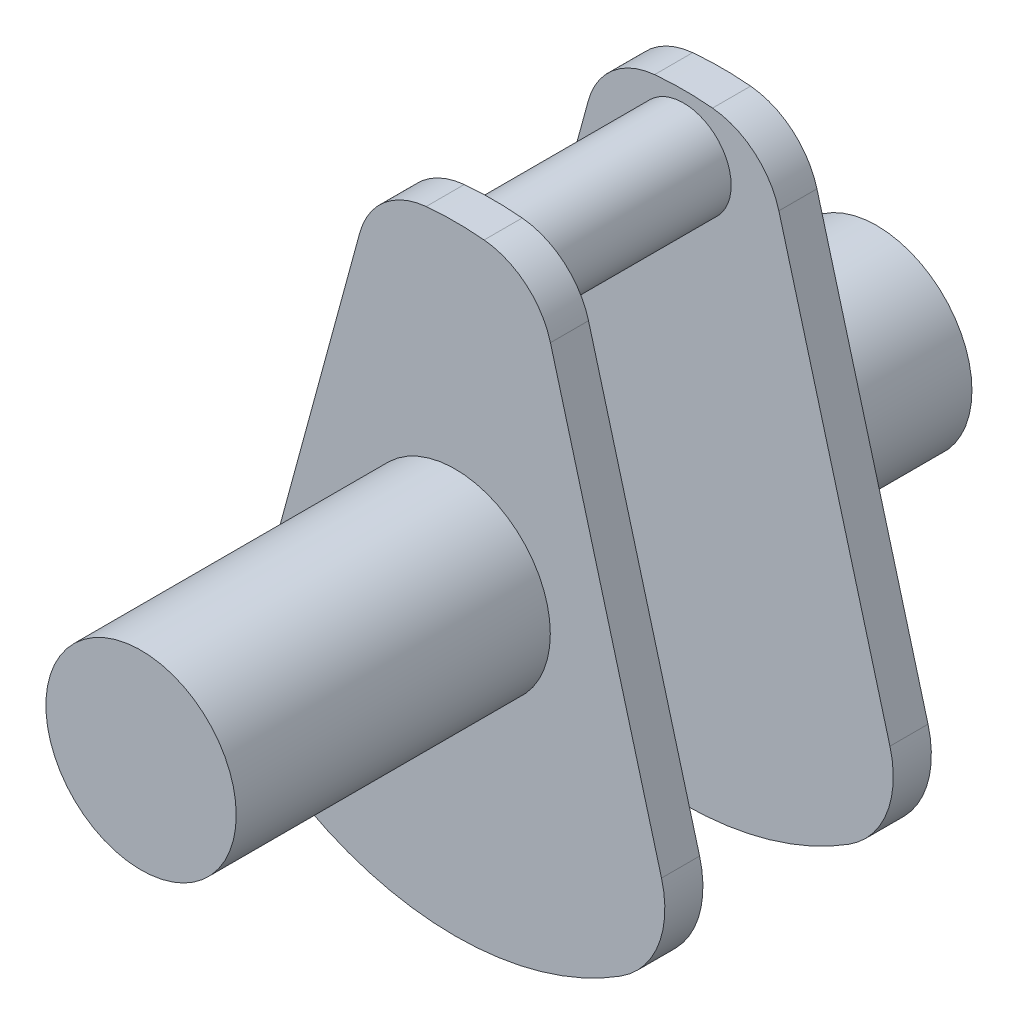
from build123d import *

# Parameters (mm, degrees)
BOSS_EXTRUDE1_DEPTH = 0.8
SKETCH2_R           = 1
BOSS_EXTRUDE2_DEPTH = 2
SKETCH3_R           = 2
BOSS_EXTRUDE3_DEPTH = 3.26
SKETCH6_R           = 2
BOSS_EXTRUDE4_DEPTH = 3.34


with BuildPart() as part:
    # Sketch1 → Boss-Extrude1 (new body)
    with BuildSketch(Plane.XY):
        with BuildLine():
            Line((-2.002843202, 5.298630925), (-4.336792166, -3.276937888))
            ThreePointArc((-4.336792166, -3.276937888), (-4.27139076, -4.52603882), (-3.476760681, -5.492006479))
            ThreePointArc((-3.476760681, -5.492006479), (0, -6.5), (3.476760681, -5.492006479))
            ThreePointArc((3.476760681, -5.492006479), (4.27139076, -4.52603882), (4.336792166, -3.276937888))
            Line((4.336792166, -3.276937888), (2.002843202, 5.298630925))
            ThreePointArc((2.002843202, 5.298630925), (1.489063424, 6.102778606), (0.608877551, 6.471419329))
            ThreePointArc((0.608877551, 6.471419329), (0, 6.5), (-0.608877551, 6.471419329))
            ThreePointArc((-0.608877551, 6.471419329), (-1.489063424, 6.102778606), (-2.002843202, 5.298630925))
        make_face()
    extrude(amount=BOSS_EXTRUDE1_DEPTH)

    # Sketch2 → Boss-Extrude2 (add)
    with BuildSketch(Plane.XY.offset(0.8)):
        with Locations((0, 5.26)):
            Circle(SKETCH2_R)
    extrude(amount=BOSS_EXTRUDE2_DEPTH)

    # Sketch3 → Boss-Extrude3 (add)
    with BuildSketch(Plane(origin=(0, 0, 0), x_dir=(-1, 0, 0), z_dir=(0, 0, -1))):
        Circle(SKETCH3_R)
    extrude(amount=BOSS_EXTRUDE3_DEPTH)

    # Mirror1: part across plane


with BuildPart() as part_1:
    add(part.part)
    add(part.part.mirror(Plane(origin=(0, 5.26, 2.8), x_dir=(1, 0, 0), z_dir=(0, 0, 1))))

    # Sketch6 → Boss-Extrude4 (add)
    with BuildSketch(Plane.XY.offset(8.86)):
        Circle(SKETCH6_R)
    extrude(amount=BOSS_EXTRUDE4_DEPTH)


solid = part_1.part
